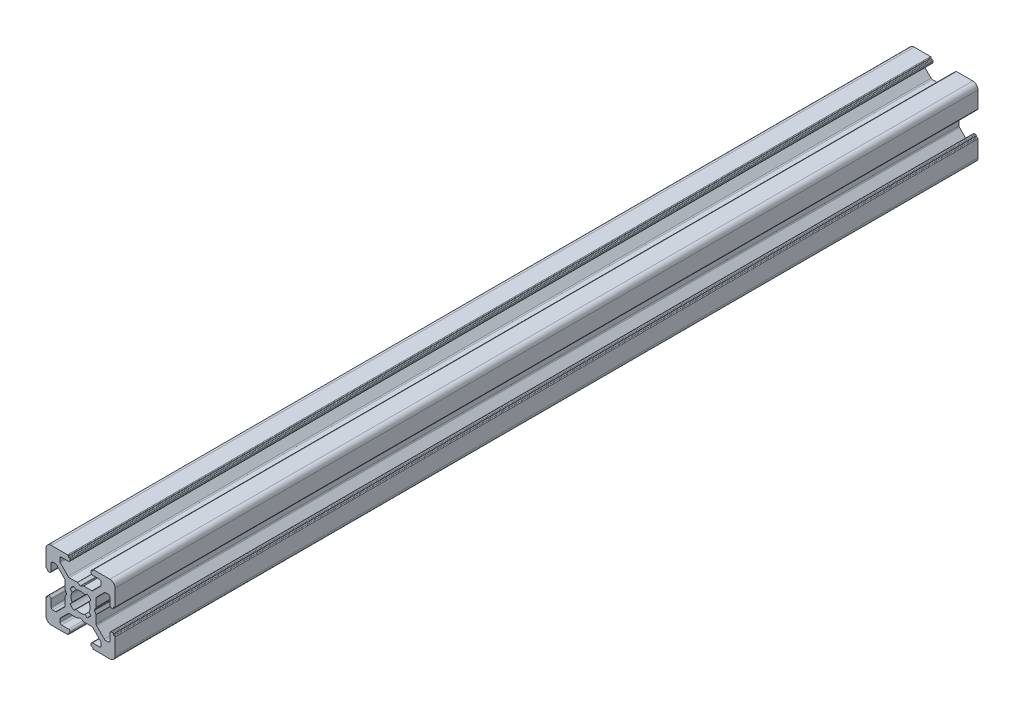
from build123d import *

# Parameters (mm, degrees)
SALIENTE_EXTRUIR_DEPTH = 250


with BuildPart() as part:
    # Croquis → Saliente_Extruir (new body)
    with BuildSketch(Plane.XY):
        with BuildLine():
            Line((6.249999773, 6.250000395), (1.5, 6.250000395))
            ThreePointArc((1.5, 6.250000395), (0.439339828, 5.810660567), (0, 4.750000395))
            Line((0, 4.750000395), (0, 0))
            ThreePointArc((0, 0), (0.058578644, -0.141421356), (0.2, -0.2))
            Line((0.2, -0.2), (0.300000268, -0.2))
            ThreePointArc((0.300000268, -0.2), (0.441421624, -0.258578644), (0.500000268, -0.4))
            Line((0.500000268, -0.4), (0.500000268, -0.549999605))
            ThreePointArc((0.500000268, -0.549999605), (0.558578912, -0.691420961), (0.700000268, -0.749999605))
            Line((0.700000268, -0.749999605), (1.000000268, -0.749999605))
            ThreePointArc((1.000000268, -0.749999605), (1.353553659, -0.603552995), (1.500000268, -0.249999605))
            Line((1.500000268, -0.249999605), (1.500000268, 1.75))
            ThreePointArc((1.500000268, 1.75), (1.646446877, 2.103553391), (2.000000268, 2.25))
            Line((2.000000268, 2.25), (2.732233315, 2.25))
            ThreePointArc((2.732233315, 2.25), (2.923575031, 2.211939766), (3.085786706, 2.103553391))
            Line((3.085786706, 2.103553391), (5.353553602, -0.164213506))
            ThreePointArc((5.353553602, -0.164213506), (5.461939977, -0.32642518), (5.500000211, -0.517766896))
            Line((5.500000211, -0.517766896), (5.500000211, -2.796410303))
            ThreePointArc((5.500000211, -2.796410303), (5.506815047, -2.848174114), (5.526795133, -2.896410307))
            Line((5.526795133, -2.896410307), (5.961880159, -3.649999636))
            ThreePointArc((5.961880159, -3.649999636), (5.988675071, -3.749999605), (5.961880159, -3.849999574))
            Line((5.961880159, -3.849999574), (5.526795133, -4.603588902))
            ThreePointArc((5.526795133, -4.603588902), (5.506815046, -4.651825095), (5.500000211, -4.703588906))
            Line((5.500000211, -4.703588906), (5.500000211, -6.982232313))
            ThreePointArc((5.500000211, -6.982232313), (5.461939977, -7.173574029), (5.353553602, -7.335785704))
            Line((5.353553602, -7.335785704), (3.085786706, -9.6035526))
            ThreePointArc((3.085786706, -9.6035526), (2.923575031, -9.711938976), (2.732233315, -9.749999209))
            Line((2.732233315, -9.749999209), (2.000000268, -9.749999209))
            ThreePointArc((2.000000268, -9.749999209), (1.646446877, -9.6035526), (1.500000268, -9.249999209))
            Line((1.500000268, -9.249999209), (1.500000268, -7.249999605))
            ThreePointArc((1.500000268, -7.249999605), (1.353553659, -6.896446214), (1.000000268, -6.749999605))
            Line((1.000000268, -6.749999605), (0.700000268, -6.749999605))
            ThreePointArc((0.700000268, -6.749999605), (0.558578912, -6.808578248), (0.500000268, -6.949999605))
            Line((0.500000268, -6.949999605), (0.500000268, -7.099999209))
            ThreePointArc((0.500000268, -7.099999209), (0.441421624, -7.241420566), (0.300000268, -7.299999209))
            Line((0.300000268, -7.299999209), (0.2, -7.299999209))
            ThreePointArc((0.2, -7.299999209), (0.058578644, -7.358577853), (0, -7.499999209))
            Line((0, -7.499999209), (0, -12.249999605))
            ThreePointArc((0, -12.249999605), (0.439339828, -13.310659776), (1.5, -13.749999605))
            Line((1.5, -13.749999605), (6.249999772, -13.749999605))
            ThreePointArc((6.249999772, -13.749999605), (6.391421129, -13.691420961), (6.449999772, -13.549999605))
            Line((6.449999772, -13.549999605), (6.449999772, -13.449999605))
            ThreePointArc((6.449999772, -13.449999605), (6.508578416, -13.308578248), (6.649999772, -13.249999605))
            Line((6.649999772, -13.249999605), (6.8, -13.249999605))
            ThreePointArc((6.8, -13.249999605), (6.941421356, -13.191420961), (7, -13.049999605))
            Line((7, -13.049999605), (7, -12.749999278))
            ThreePointArc((7, -12.749999278), (6.853553391, -12.396445888), (6.5, -12.249999278))
            Line((6.5, -12.249999278), (4.499999314, -12.249999278))
            ThreePointArc((4.499999314, -12.249999278), (4.146445923, -12.103552669), (3.999999314, -11.749999278))
            Line((3.999999314, -11.749999278), (3.999999314, -11.017766231))
            ThreePointArc((3.999999314, -11.017766231), (4.038059552, -10.826424504), (4.146445941, -10.664212823))
            Line((4.146445941, -10.664212823), (6.414212788, -8.396446197))
            ThreePointArc((6.414212788, -8.396446197), (6.576424456, -8.288059834), (6.767766161, -8.249999605))
            Line((6.767766161, -8.249999605), (9.046409688, -8.249999605))
            ThreePointArc((9.046409688, -8.249999605), (9.098173495, -8.243184771), (9.146409684, -8.223204688))
            Line((9.146409684, -8.223204688), (9.899999955, -7.788119166))
            ThreePointArc((9.899999955, -7.788119166), (10, -7.761324236), (10.100000045, -7.788119166))
            Line((10.100000045, -7.788119166), (10.853590316, -8.223204688))
            ThreePointArc((10.853590316, -8.223204688), (10.901826505, -8.243184771), (10.953590312, -8.249999605))
            Line((10.953590312, -8.249999605), (13.232233839, -8.249999605))
            ThreePointArc((13.232233839, -8.249999605), (13.423575544, -8.288059834), (13.585787212, -8.396446197))
            Line((13.585787212, -8.396446197), (15.853554059, -10.664212823))
            ThreePointArc((15.853554059, -10.664212823), (15.961940448, -10.826424504), (16.000000686, -11.017766231))
            Line((16.000000686, -11.017766231), (16.000000686, -11.749999278))
            ThreePointArc((16.000000686, -11.749999278), (15.853554077, -12.103552669), (15.500000686, -12.249999278))
            Line((15.500000686, -12.249999278), (13.5, -12.249999278))
            ThreePointArc((13.5, -12.249999278), (13.146446609, -12.396445888), (13, -12.749999278))
            Line((13, -12.749999278), (13, -13.049999605))
            ThreePointArc((13, -13.049999605), (13.058578644, -13.191420961), (13.2, -13.249999605))
            Line((13.2, -13.249999605), (13.350000227, -13.249999605))
            ThreePointArc((13.350000227, -13.249999605), (13.491421584, -13.308578248), (13.550000227, -13.449999605))
            Line((13.550000227, -13.449999605), (13.550000227, -13.549999605))
            ThreePointArc((13.550000227, -13.549999605), (13.608578871, -13.691420961), (13.750000227, -13.749999605))
            Line((13.750000227, -13.749999605), (18.5, -13.749999605))
            ThreePointArc((18.5, -13.749999605), (19.560660172, -13.310659776), (20, -12.249999605))
            Line((20, -12.249999605), (20, -7.499999209))
            ThreePointArc((20, -7.499999209), (19.941421356, -7.358577853), (19.8, -7.299999209))
            Line((19.8, -7.299999209), (19.699999732, -7.299999209))
            ThreePointArc((19.699999732, -7.299999209), (19.558578376, -7.241420566), (19.499999732, -7.099999209))
            Line((19.499999732, -7.099999209), (19.499999732, -6.949999605))
            ThreePointArc((19.499999732, -6.949999605), (19.441421088, -6.808578248), (19.299999732, -6.749999605))
            Line((19.299999732, -6.749999605), (18.999999732, -6.749999605))
            ThreePointArc((18.999999732, -6.749999605), (18.646446341, -6.896446214), (18.499999732, -7.249999605))
            Line((18.499999732, -7.249999605), (18.499999732, -9.249999209))
            ThreePointArc((18.499999732, -9.249999209), (18.353553123, -9.6035526), (17.999999732, -9.749999209))
            Line((17.999999732, -9.749999209), (17.267766685, -9.749999209))
            ThreePointArc((17.267766685, -9.749999209), (17.076424969, -9.711938976), (16.914213294, -9.6035526))
            Line((16.914213294, -9.6035526), (14.646446398, -7.335785704))
            ThreePointArc((14.646446398, -7.335785704), (14.538060023, -7.173574029), (14.499999789, -6.982232313))
            Line((14.499999789, -6.982232313), (14.499999789, -4.703588906))
            ThreePointArc((14.499999789, -4.703588906), (14.493184953, -4.651825095), (14.473204867, -4.603588902))
            Line((14.473204867, -4.603588902), (14.038119841, -3.849999574))
            ThreePointArc((14.038119841, -3.849999574), (14.011324929, -3.749999605), (14.038119841, -3.649999636))
            Line((14.038119841, -3.649999636), (14.473204867, -2.896410307))
            ThreePointArc((14.473204867, -2.896410307), (14.493184953, -2.848174114), (14.499999789, -2.796410303))
            Line((14.499999789, -2.796410303), (14.499999789, -0.517766896))
            ThreePointArc((14.499999789, -0.517766896), (14.538060023, -0.32642518), (14.646446398, -0.164213506))
            Line((14.646446398, -0.164213506), (16.914213294, 2.103553391))
            ThreePointArc((16.914213294, 2.103553391), (17.076424969, 2.211939766), (17.267766685, 2.25))
            Line((17.267766685, 2.25), (17.999999732, 2.25))
            ThreePointArc((17.999999732, 2.25), (18.353553123, 2.103553391), (18.499999732, 1.75))
            Line((18.499999732, 1.75), (18.499999732, -0.249999605))
            ThreePointArc((18.499999732, -0.249999605), (18.646446341, -0.603552995), (18.999999732, -0.749999605))
            Line((18.999999732, -0.749999605), (19.299999732, -0.749999605))
            ThreePointArc((19.299999732, -0.749999605), (19.441421088, -0.691420961), (19.499999732, -0.549999605))
            Line((19.499999732, -0.549999605), (19.499999732, -0.4))
            ThreePointArc((19.499999732, -0.4), (19.558578376, -0.258578644), (19.699999732, -0.2))
            Line((19.699999732, -0.2), (19.8, -0.2))
            ThreePointArc((19.8, -0.2), (19.941421356, -0.141421356), (20, 0))
            Line((20, 0), (20, 4.750000395))
            ThreePointArc((20, 4.750000395), (19.560660172, 5.810660567), (18.5, 6.250000395))
            Line((18.5, 6.250000395), (13.750000228, 6.250000395))
            ThreePointArc((13.750000228, 6.250000395), (13.608578871, 6.191421752), (13.550000228, 6.050000395))
            Line((13.550000228, 6.050000395), (13.550000228, 5.950000395))
            ThreePointArc((13.550000228, 5.950000395), (13.491421584, 5.808579039), (13.350000228, 5.750000395))
            Line((13.350000228, 5.750000395), (13.2, 5.750000395))
            ThreePointArc((13.2, 5.750000395), (13.058578644, 5.691421752), (13, 5.550000395))
            Line((13, 5.550000395), (13, 5.250000069))
            ThreePointArc((13, 5.250000069), (13.146446609, 4.896446678), (13.5, 4.750000069))
            Line((13.5, 4.750000069), (15.500000686, 4.750000069))
            ThreePointArc((15.500000686, 4.750000069), (15.853554077, 4.603553459), (16.000000686, 4.250000069))
            Line((16.000000686, 4.250000069), (16.000000686, 3.517767022))
            ThreePointArc((16.000000686, 3.517767022), (15.961940448, 3.326425294), (15.853554059, 3.164213614))
            Line((15.853554059, 3.164213614), (13.585787212, 0.896446988))
            ThreePointArc((13.585787212, 0.896446988), (13.423575544, 0.788060624), (13.232233839, 0.750000395))
            Line((13.232233839, 0.750000395), (10.953590312, 0.750000395))
            ThreePointArc((10.953590312, 0.750000395), (10.901826505, 0.743185561), (10.853590316, 0.723205479))
            Line((10.853590316, 0.723205479), (10.100000045, 0.288119957))
            ThreePointArc((10.100000045, 0.288119957), (10, 0.261325027), (9.899999955, 0.288119957))
            Line((9.899999955, 0.288119957), (9.146409684, 0.723205479))
            ThreePointArc((9.146409684, 0.723205479), (9.098173495, 0.743185561), (9.046409688, 0.750000395))
            Line((9.046409688, 0.750000395), (6.767766161, 0.750000395))
            ThreePointArc((6.767766161, 0.750000395), (6.576424456, 0.788060624), (6.414212788, 0.896446988))
            Line((6.414212788, 0.896446988), (4.146445941, 3.164213614))
            ThreePointArc((4.146445941, 3.164213614), (4.038059552, 3.326425294), (3.999999314, 3.517767022))
            Line((3.999999314, 3.517767022), (3.999999314, 4.250000069))
            ThreePointArc((3.999999314, 4.250000069), (4.146445923, 4.603553459), (4.499999314, 4.750000069))
            Line((4.499999314, 4.750000069), (6.5, 4.750000069))
            ThreePointArc((6.5, 4.750000069), (6.853553391, 4.896446678), (7, 5.250000069))
            Line((7, 5.250000069), (7, 5.550000395))
            ThreePointArc((7, 5.550000395), (6.941421356, 5.691421752), (6.8, 5.750000395))
            Line((6.8, 5.750000395), (6.649999772, 5.750000395))
            ThreePointArc((6.649999772, 5.750000395), (6.508578416, 5.808579039), (6.449999772, 5.950000395))
            Line((6.449999772, 5.950000395), (6.449999772, 6.050000395))
            ThreePointArc((6.449999772, 6.050000395), (6.391421129, 6.191421752), (6.249999773, 6.250000395))
        make_face()
        with BuildLine():
            Line((7.007825047, -1.840068643), (7.554704576, -2.491814288))
            ThreePointArc((7.554704576, -2.491814288), (7.25, -3.749999605), (7.554704576, -5.008184922))
            Line((7.554704576, -5.008184922), (7.007825046, -5.659930566))
            ThreePointArc((7.007825046, -5.659930566), (7.488262739, -6.25841009), (8.08610498, -6.739640567))
            Line((8.08610498, -6.739640567), (8.741814564, -6.195294967))
            ThreePointArc((8.741814564, -6.195294967), (10, -6.499999605), (11.258185436, -6.195294967))
            Line((11.258185436, -6.195294967), (11.913895019, -6.739640567))
            ThreePointArc((11.913895019, -6.739640567), (12.511737261, -6.25841009), (12.992174953, -5.659930566))
            Line((12.992174953, -5.659930566), (12.445295423, -5.008184922))
            ThreePointArc((12.445295423, -5.008184922), (12.75, -3.749999605), (12.445295423, -2.491814288))
            Line((12.445295423, -2.491814288), (12.992174953, -1.840068643))
            ThreePointArc((12.992174953, -1.840068643), (12.511737261, -1.241589119), (11.913895019, -0.760358642))
            Line((11.913895019, -0.760358642), (11.258185436, -1.304704243))
            ThreePointArc((11.258185436, -1.304704243), (10, -0.999999605), (8.741814564, -1.304704243))
            Line((8.741814564, -1.304704243), (8.08610498, -0.760358642))
            ThreePointArc((8.08610498, -0.760358642), (7.488262739, -1.241589119), (7.007825047, -1.840068643))
        make_face(mode=Mode.SUBTRACT)
    extrude(amount=SALIENTE_EXTRUIR_DEPTH)


solid = part.part
